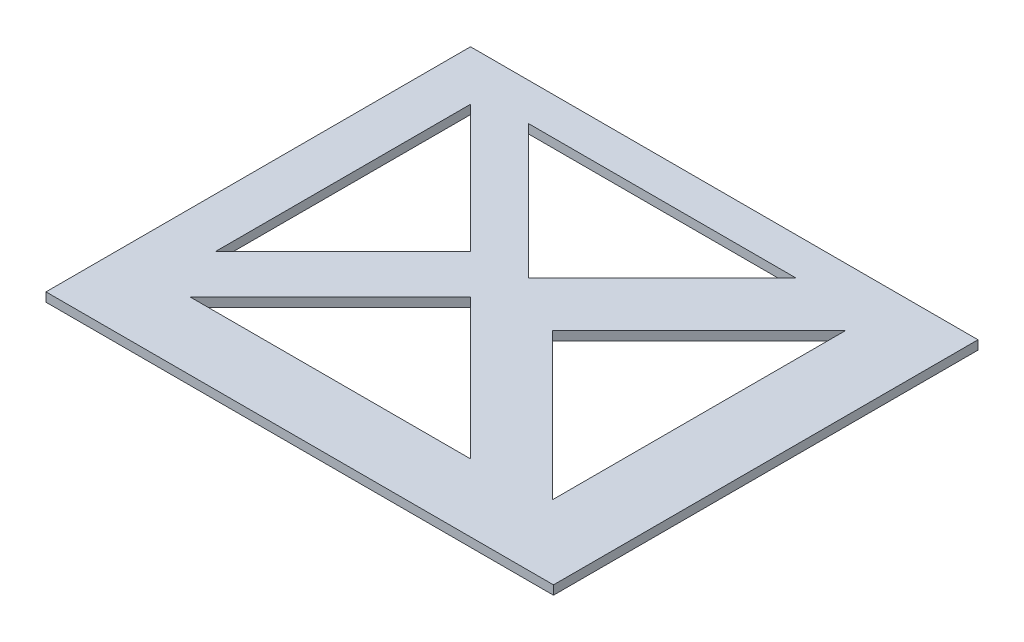
from build123d import *

# Parameters (mm, degrees)
SKETCH_1_W          = 100
SKETCH_1_H          = 100
EXTRUDE_1_DEPTH     = 10
CUT_EXTRUDE_1_DEPTH = 10
SKETCH_3_W          = 56.365102816
SKETCH_3_H          = 47.150770251
CUT_EXTRUDE_2_DEPTH = 9


with BuildPart() as part:
    # 草图1 → 凸台-拉伸1 (new body)
    with BuildSketch(Plane(origin=(0, 0, 0), x_dir=(1, 0, 0), z_dir=(0, 1, 0))):
        with Locations((-80.040161423, 118.55773228)):
            Rectangle(SKETCH_1_W, SKETCH_1_H)
        Polygon((-124.50987816, 163.027449017), (-124.50987816, 134.743177769), (-110.367742536, 148.885313393), align=None, mode=Mode.SUBTRACT)
        Polygon((-119.453493398, 164.389725441), (-104.604250993, 149.540483036), (-89.755008588, 164.389725441), align=None, mode=Mode.SUBTRACT)
        Polygon((-105.956547691, 144.474118548), (-121.512896877, 128.917769362), (-90.400198505, 128.917769362), align=None, mode=Mode.SUBTRACT)
        Polygon((-81.914917131, 162.05369475), (-98.178373098, 145.790238783), (-81.914917131, 129.526782816), align=None, mode=Mode.SUBTRACT)
    extrude(amount=EXTRUDE_1_DEPTH)

    # 草图2 → 切除-拉伸1 (cut)
    with BuildSketch(Plane(origin=(0, 10, 0), x_dir=(1, 0, 0), z_dir=(0, 1, 0))):
        Polygon((-130.040161423, 121.406962029), (-73.675058607, 121.406962029), (-73.675058607, 168.55773228), (-30.040161423, 168.55773228), (-30.040161423, 68.55773228), (-130.040161423, 68.55773228), align=None)
    extrude(amount=-CUT_EXTRUDE_1_DEPTH, mode=Mode.SUBTRACT)

    # 草图3 → 切除-拉伸2 (cut)
    with BuildSketch(Plane(origin=(0, 10, 0), x_dir=(1, 0, 0), z_dir=(0, 1, 0))):
        with Locations((-101.857610015, 144.982347155)):
            Rectangle(SKETCH_3_W, SKETCH_3_H)
    extrude(amount=-CUT_EXTRUDE_2_DEPTH, mode=Mode.SUBTRACT)


solid = part.part
